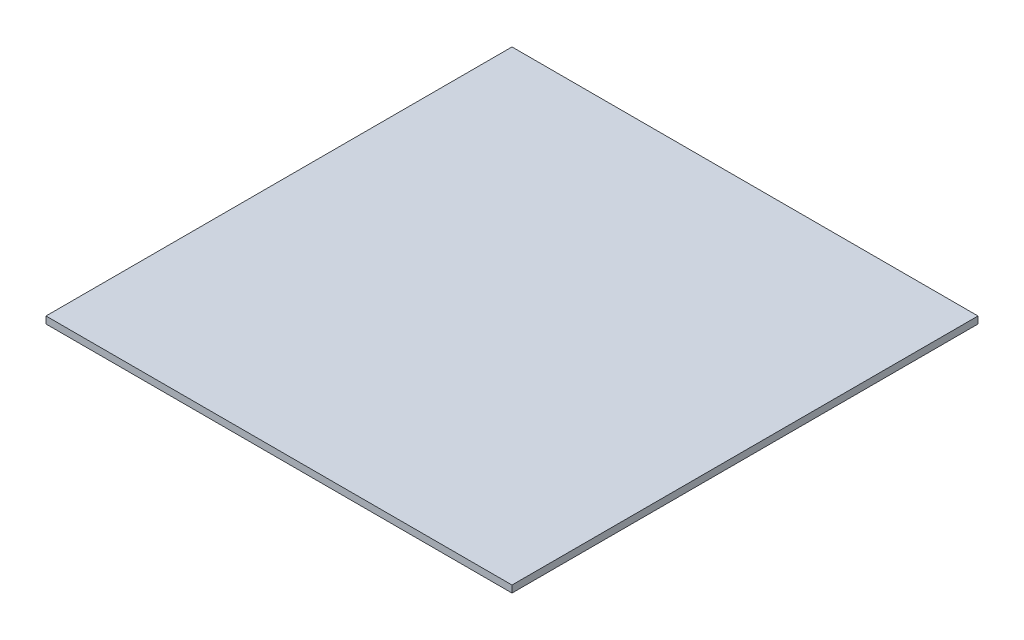
from build123d import *

# Parameters (mm, degrees)
SKETCH1_W           = 50.8
SKETCH1_H           = 50.8
BOSS_EXTRUDE1_DEPTH = 0.762


with BuildPart() as part:
    # Sketch1 → Boss-Extrude1 (new body)
    with BuildSketch(Plane(origin=(0, 0, 0), x_dir=(1, 0, 0), z_dir=(0, 1, 0))):
        Rectangle(SKETCH1_W, SKETCH1_H)
    extrude(amount=BOSS_EXTRUDE1_DEPTH)


solid = part.part
